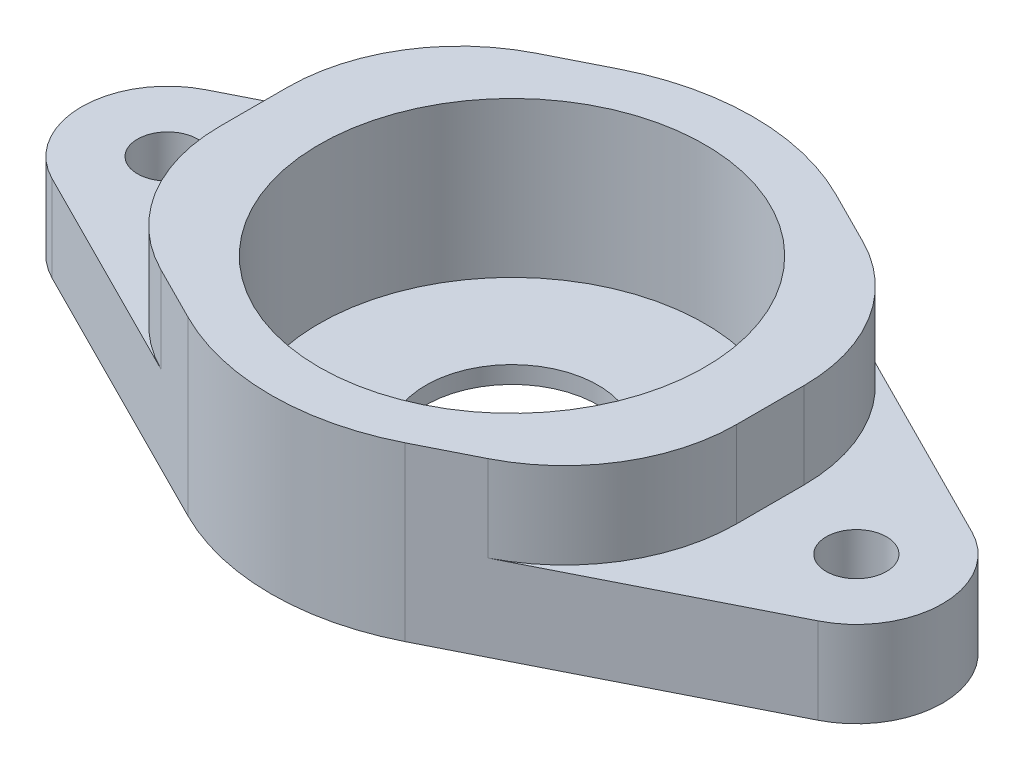
from build123d import *

# Parameters (mm, degrees)
SKETCH2_R               = 1.75
BOSS_EXTRUDE1_DEPTH     = 10
SKETCH3_R               = 11.2
CUT_EXTRUDE1_DEPTH      = 9
SKETCH4_W               = 10
SKETCH4_H               = 5
CUT_EXTRUDE2_DEPTH      = 15
CUT_EXTRUDE2_DEPTH_BACK = 15
FILLET1_R               = 10
SKETCH5_R               = 5
CUT_EXTRUDE3_DEPTH      = 10
CUT_EXTRUDE3_DEPTH_BACK = 2


with BuildPart() as part:
    # Sketch2 → Boss-Extrude1 (new body)
    with BuildSketch(Plane(origin=(0, 0, 0), x_dir=(1, 0, 0), z_dir=(0, 1, 0))):
        with BuildLine():
            Line((-22.25, 4.465142775), (-6.3, 12.50239977))
            ThreePointArc((-6.3, 12.50239977), (0, 14), (6.3, 12.50239977))
            Line((6.3, 12.50239977), (22.25, 4.465142775))
            ThreePointArc((22.25, 4.465142775), (25, 0), (22.25, -4.465142775))
            Line((22.25, -4.465142775), (6.3, -12.50239977))
            ThreePointArc((6.3, -12.50239977), (0, -14), (-6.3, -12.50239977))
            Line((-6.3, -12.50239977), (-22.25, -4.465142775))
            ThreePointArc((-22.25, -4.465142775), (-25, 0), (-22.25, 4.465142775))
        make_face()
        with Locations((-20, 0)):
            Circle(SKETCH2_R, mode=Mode.SUBTRACT)
        with Locations((20, 0)):
            Circle(SKETCH2_R, mode=Mode.SUBTRACT)
    extrude(amount=BOSS_EXTRUDE1_DEPTH)

    # Sketch3 → Cut-Extrude1 (cut)
    with BuildSketch(Plane(origin=(0, 10, 0), x_dir=(1, 0, 0), z_dir=(0, 1, 0))):
        Circle(SKETCH3_R)
    extrude(amount=-CUT_EXTRUDE1_DEPTH, mode=Mode.SUBTRACT)

    # Sketch4 → Cut-Extrude2 (cut, two sides)
    with BuildSketch(Plane.XY) as cut_extrude2_sk:
        with Locations((-20, 7.5)):
            Rectangle(SKETCH4_W, SKETCH4_H)
        with Locations((20, 7.5)):
            Rectangle(SKETCH4_W, SKETCH4_H)
    extrude(amount=CUT_EXTRUDE2_DEPTH, mode=Mode.SUBTRACT)
    extrude(cut_extrude2_sk.sketch, amount=-CUT_EXTRUDE2_DEPTH_BACK, mode=Mode.SUBTRACT)

    # Fillet1
    fillet1_edges = [part.edges().sort_by_distance(p)[0] for p in [
        (-15, 7.5, -8.118441409),
        (15, 7.5, -8.118441409),
        (-15, 7.5, 8.118441409),
        (15, 7.5, 8.118441409),
    ]]
    fillet(fillet1_edges, radius=FILLET1_R)

    # Sketch5 → Cut-Extrude3 (cut, two sides)
    with BuildSketch(Plane(origin=(0, 1, 0), x_dir=(1, 0, 0), z_dir=(0, 1, 0))) as cut_extrude3_sk:
        Circle(SKETCH5_R)
    extrude(amount=CUT_EXTRUDE3_DEPTH, mode=Mode.SUBTRACT)
    extrude(cut_extrude3_sk.sketch, amount=-CUT_EXTRUDE3_DEPTH_BACK, mode=Mode.SUBTRACT)


solid = part.part
